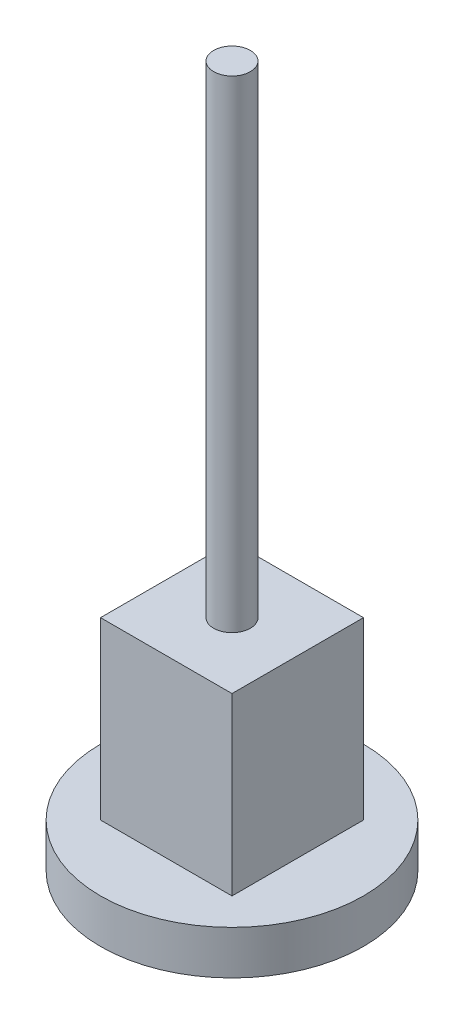
from build123d import *

# Parameters (mm, degrees)
SKETCH1_R           = 30
BOSS_EXTRUDE1_DEPTH = 10
SKETCH2_W           = 30
SKETCH2_H           = 30
BOSS_EXTRUDE2_DEPTH = 40
SKETCH3_R           = 4.196967066
BOSS_EXTRUDE3_DEPTH = 110


with BuildPart() as part:
    # Sketch1 → Boss-Extrude1 (new body)
    with BuildSketch(Plane(origin=(0, 0, 0), x_dir=(1, 0, 0), z_dir=(0, 1, 0))):
        Circle(SKETCH1_R)
    extrude(amount=BOSS_EXTRUDE1_DEPTH)

    # Sketch2 → Boss-Extrude2 (add)
    with BuildSketch(Plane(origin=(0, 10, 0), x_dir=(1, 0, 0), z_dir=(0, 1, 0))):
        Rectangle(SKETCH2_W, SKETCH2_H)
    extrude(amount=BOSS_EXTRUDE2_DEPTH)

    # Sketch3 → Boss-Extrude3 (add)
    with BuildSketch(Plane(origin=(0, 50, 0), x_dir=(1, 0, 0), z_dir=(0, 1, 0))):
        Circle(SKETCH3_R)
    extrude(amount=BOSS_EXTRUDE3_DEPTH)


solid = part.part
